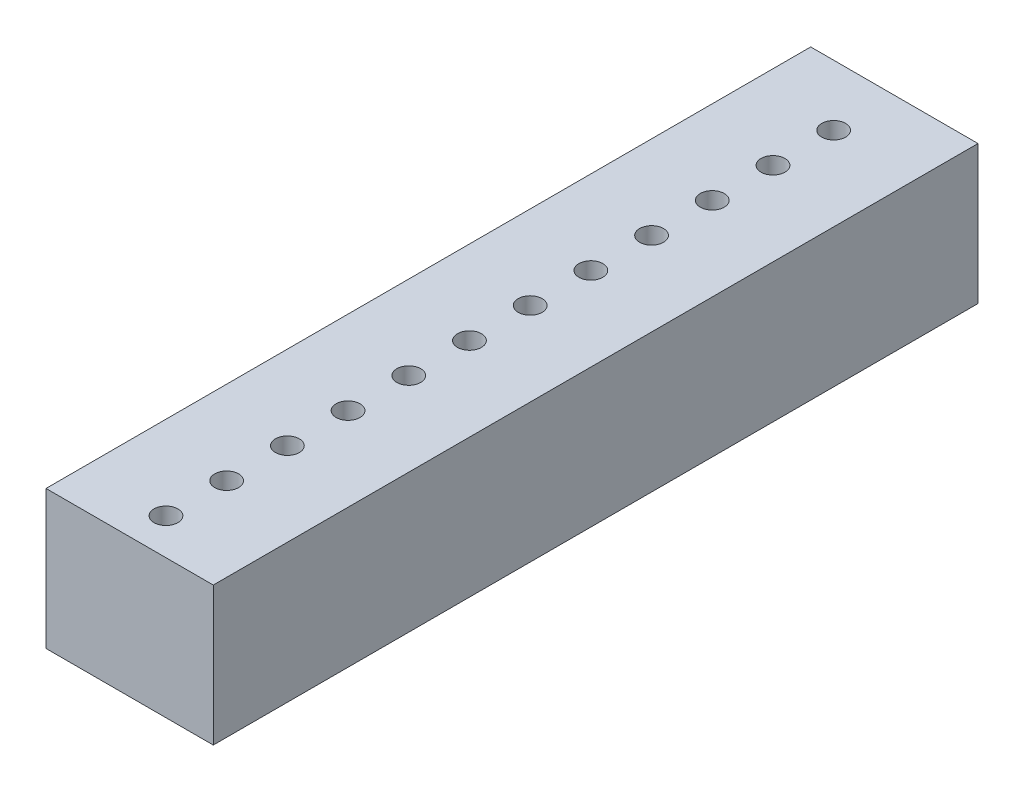
from build123d import *

# Parameters (mm, degrees)
SKETCH1_W           = 7
SKETCH1_H           = 32
BOSS_EXTRUDE1_DEPTH = 2.9
SKETCH2_R           = 0.5
CUT_EXTRUDE1_DEPTH  = 6.8
LPATTERN1_COUNT     = 12
LPATTERN1_PITCH     = 2.54


with BuildPart() as part:
    # Sketch1 → Boss-Extrude1 (new body, symmetric)
    with BuildSketch(Plane(origin=(0, 0, 0), x_dir=(1, 0, 0), z_dir=(0, 1, 0))):
        Rectangle(SKETCH1_W, SKETCH1_H)
    extrude(amount=BOSS_EXTRUDE1_DEPTH, both=True)

    # Sketch2 → Cut-Extrude1 (cut, through all)
    with BuildSketch(Plane(origin=(0, 2.9, 0), x_dir=(1, 0, 0), z_dir=(0, 1, 0))):
        with Locations((0, 13.46)):
            Circle(SKETCH2_R)
    cut_extrude1 = extrude(amount=-CUT_EXTRUDE1_DEPTH, mode=Mode.SUBTRACT)

    # LPattern1: Cut-Extrude1 ×12
    with Locations(*[(0, 0, i * LPATTERN1_PITCH) for i in range(1, LPATTERN1_COUNT)]):
        add(cut_extrude1, mode=Mode.SUBTRACT)


solid = part.part
